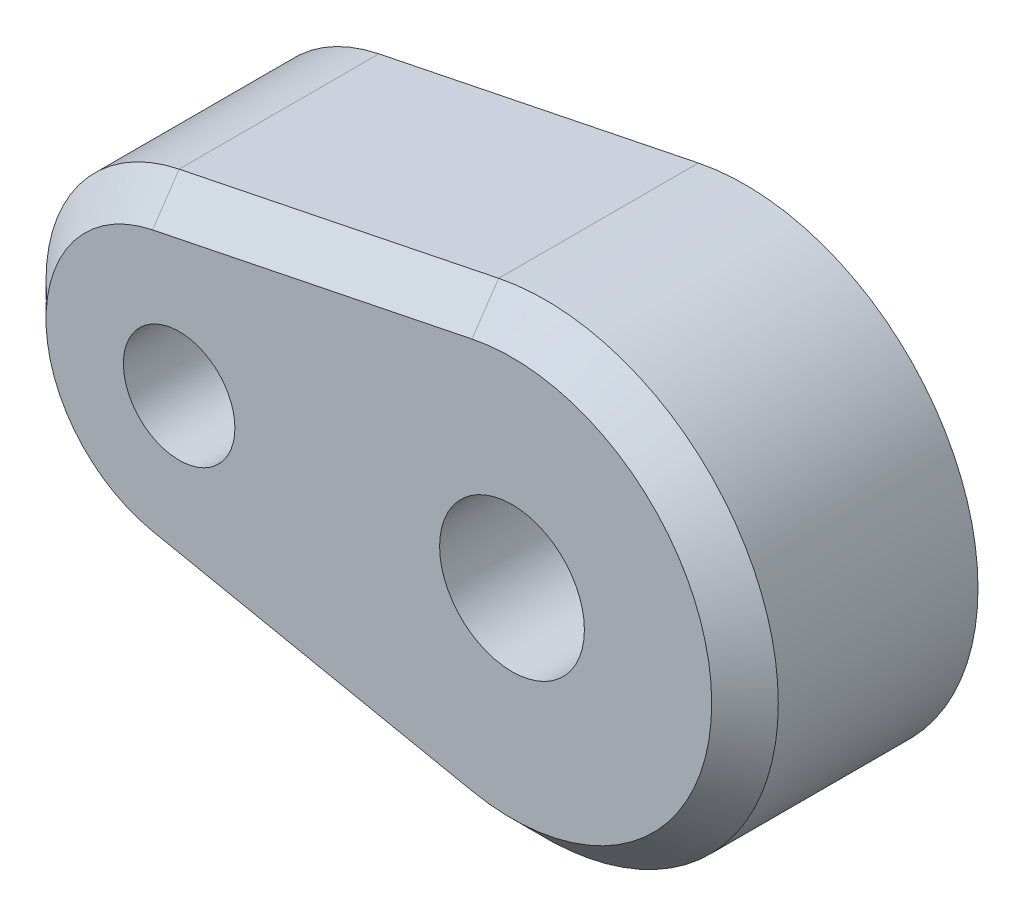
from build123d import *

# Parameters (mm, degrees)
SKETCH1_R           = 2.175
SKETCH1_R_2         = 1.675
BOSS_EXTRUDE1_DEPTH = 7
SKETCH2_R           = 4.35
CUT_EXTRUDE1_DEPTH  = 3.4
CHAMFER1_SIZE       = 1
CHAMFER2_SIZE       = 0.5


with BuildPart() as part:
    # Sketch1 → Boss-Extrude1 (new body)
    with BuildSketch(Plane.XY):
        with BuildLine():
            Line((-1.4, 6.85857128), (-11, 4.898979486))
            ThreePointArc((-11, 4.898979486), (-15, 0), (-11, -4.898979486))
            Line((-11, -4.898979486), (-1.4, -6.85857128))
            ThreePointArc((-1.4, -6.85857128), (7, 0), (-1.4, 6.85857128))
        make_face()
        Circle(SKETCH1_R, mode=Mode.SUBTRACT)
        with Locations((-10, 0)):
            Circle(SKETCH1_R_2, mode=Mode.SUBTRACT)
    extrude(amount=BOSS_EXTRUDE1_DEPTH)

    # Sketch2 → Cut-Extrude1 (cut)
    with BuildSketch(Plane(origin=(0, 0, 0), x_dir=(-1, 0, 0), z_dir=(0, 0, -1))):
        Circle(SKETCH2_R)
    extrude(amount=-CUT_EXTRUDE1_DEPTH, mode=Mode.SUBTRACT)

    # Chamfer1
    chamfer1_edges = [part.edges().sort_by_distance(p)[0] for p in [
        (-15, 0, 7),
        (-6.2, -5.878775383, 7),
        (7, 0, 7),
        (-6.2, 5.878775383, 7),
    ]]
    chamfer(chamfer1_edges, length=CHAMFER1_SIZE)

    # Chamfer2
    chamfer2_edges = [part.edges().sort_by_distance(p)[0] for p in [
        (-11.675, 0, 0),
        (4.35, 0, 0),
    ]]
    chamfer(chamfer2_edges, length=CHAMFER2_SIZE)


solid = part.part
